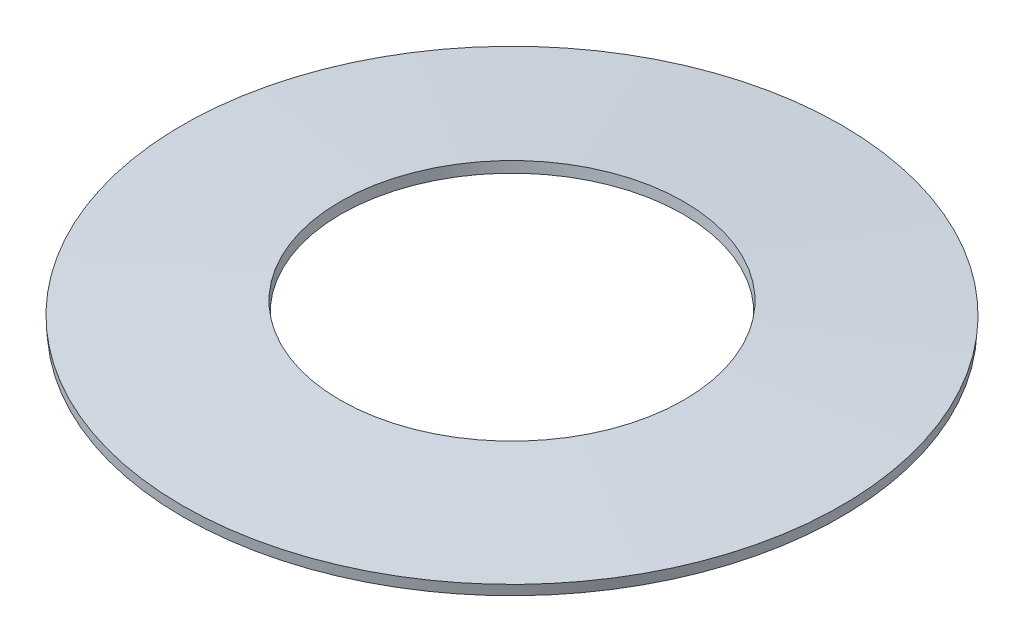
from build123d import *


with BuildPart() as part:
    # Sketch1 → Revolve1 (revolve)
    with BuildSketch(Plane.XY):
        Polygon((7.880170206, 0), (4.1, 0.300787682), (4.119829794, 0.55), (7.9, 0.249212318), align=None)
    revolve(axis=Axis((0, 0, 0), (0, 1, 0)))


solid = part.part
